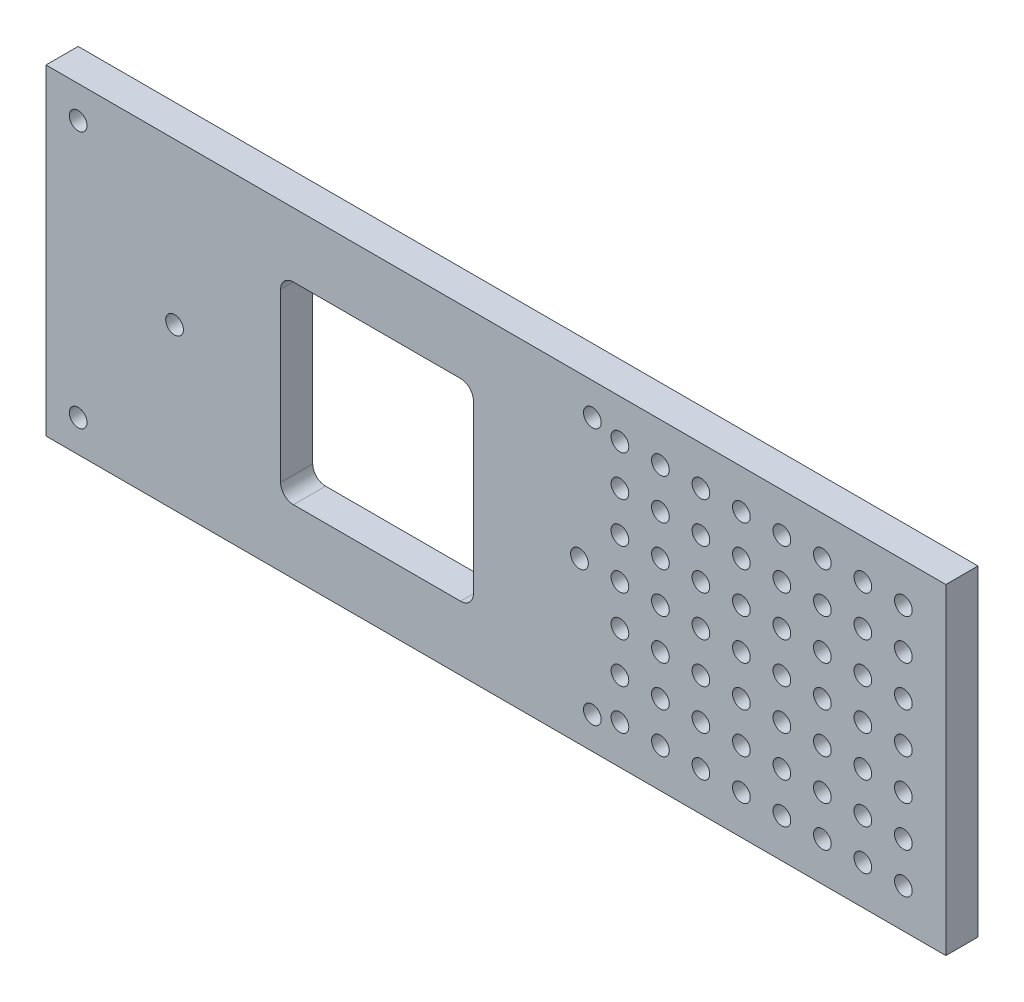
from build123d import *

# Parameters (mm, degrees)
SKETCH2_W            = 114.3
SKETCH2_H            = 63.5
BOSS_EXTRUDE1_DEPTH  = 6.35
SKETCH3_R            = 1.75
CUT_EXTRUDE1_DEPTH   = 7.35
SKETCH4_W            = 63.5
SKETCH4_H            = 63.5
BOSS_EXTRUDE2_DEPTH  = 6.35
SKETCH5_R            = 1.75
CUT_EXTRUDE2_DEPTH   = 7.35
LPATTERN1_COUNT      = 8
LPATTERN1_PITCH      = 8
LPATTERN1_COUNT_DIR2 = 4
LPATTERN1_PITCH_DIR2 = 8
LPATTERN2_COUNT      = 8
LPATTERN2_PITCH      = 8
LPATTERN2_COUNT_DIR2 = 4
LPATTERN2_PITCH_DIR2 = 8
SKETCH6_W            = 38.1
SKETCH6_H            = 38.1
CUT_EXTRUDE3_DEPTH   = 7.35
FILLET1_R            = 2.54


with BuildPart() as part:
    # Sketch2 → Boss-Extrude1 (new body)
    with BuildSketch(Plane.XY):
        with Locations((57.15, 31.75)):
            Rectangle(SKETCH2_W, SKETCH2_H)
    extrude(amount=BOSS_EXTRUDE1_DEPTH)

    # Sketch3 → Cut-Extrude1 (cut, through all)
    with BuildSketch(Plane.XY.offset(6.35)):
        with Locations((25.4, 31.75)):
            Circle(SKETCH3_R)
        with Locations((105.4, 31.75)):
            Circle(SKETCH3_R)
        with Locations((6.35, 57.15)):
            Circle(SKETCH3_R)
        with Locations((6.35, 6.35)):
            Circle(SKETCH3_R)
        with Locations((107.95, 6.35)):
            Circle(SKETCH3_R)
        with Locations((107.95, 57.15)):
            Circle(SKETCH3_R)
    extrude(amount=-CUT_EXTRUDE1_DEPTH, mode=Mode.SUBTRACT)

    # Sketch4 → Boss-Extrude2 (add, through all)
    with BuildSketch(Plane.XY.offset(6.35)):
        with Locations((146.05, 31.75)):
            Rectangle(SKETCH4_W, SKETCH4_H)
    extrude(amount=-BOSS_EXTRUDE2_DEPTH)

    # Sketch5 → Cut-Extrude2 (cut, through all)
    with BuildSketch(Plane.XY.offset(6.35)):
        with Locations((113.4, 31.75)):
            Circle(SKETCH5_R)
    cut_extrude2 = extrude(amount=-CUT_EXTRUDE2_DEPTH, mode=Mode.SUBTRACT)

    # LPattern1: Cut-Extrude2 8 × 4
    with Locations(*[(i * LPATTERN1_PITCH, -j * LPATTERN1_PITCH_DIR2, 0) for i in range(LPATTERN1_COUNT) for j in range(LPATTERN1_COUNT_DIR2) if (i, j) != (0, 0)]):
        add(cut_extrude2, mode=Mode.SUBTRACT)

    # LPattern2: Cut-Extrude2 8 × 4
    with Locations(*[(i * LPATTERN2_PITCH, j * LPATTERN2_PITCH_DIR2, 0) for i in range(LPATTERN2_COUNT) for j in range(LPATTERN2_COUNT_DIR2) if (i, j) != (0, 0)]):
        add(cut_extrude2, mode=Mode.SUBTRACT)

    # Sketch6 → Cut-Extrude3 (cut, through all)
    with BuildSketch(Plane.XY.offset(6.35)):
        with Locations((65.4, 31.75)):
            Rectangle(SKETCH6_W, SKETCH6_H)
    extrude(amount=-CUT_EXTRUDE3_DEPTH, mode=Mode.SUBTRACT)

    # Fillet1
    fillet1_edges = [part.edges().sort_by_distance(p)[0] for p in [
        (46.35, 12.7, 3.175),
        (46.35, 50.8, 3.175),
        (84.45, 50.8, 3.175),
        (84.45, 12.7, 3.175),
    ]]
    fillet(fillet1_edges, radius=FILLET1_R)


solid = part.part
